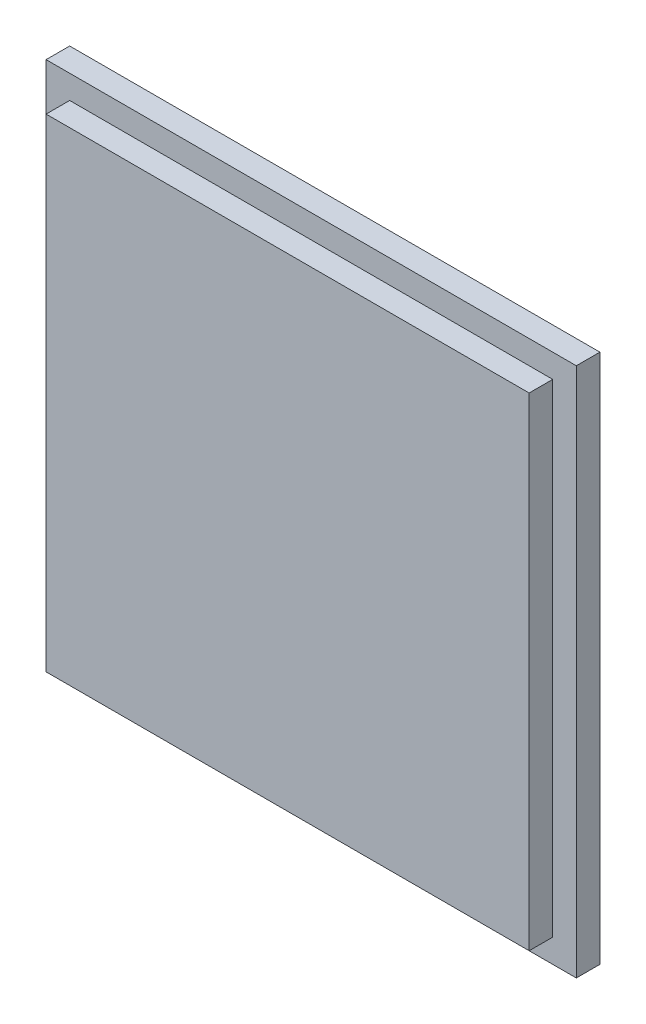
from build123d import *

# Parameters (mm, degrees)
SKETCH2_W           = 56.2
SKETCH2_H           = 56.2
BOSS_EXTRUDE1_DEPTH = 2.5
SKETCH3_W           = 51.2
SKETCH3_H           = 51.2
BOSS_EXTRUDE2_DEPTH = 2.5


with BuildPart() as part:
    # Sketch2 → Boss-Extrude1 (new body)
    with BuildSketch(Plane.XY):
        Rectangle(SKETCH2_W, SKETCH2_H)
    extrude(amount=BOSS_EXTRUDE1_DEPTH)

    # Sketch3 → Boss-Extrude2 (add)
    with BuildSketch(Plane.XY.offset(2.5)):
        Rectangle(SKETCH3_W, SKETCH3_H)
    extrude(amount=BOSS_EXTRUDE2_DEPTH)


solid = part.part
